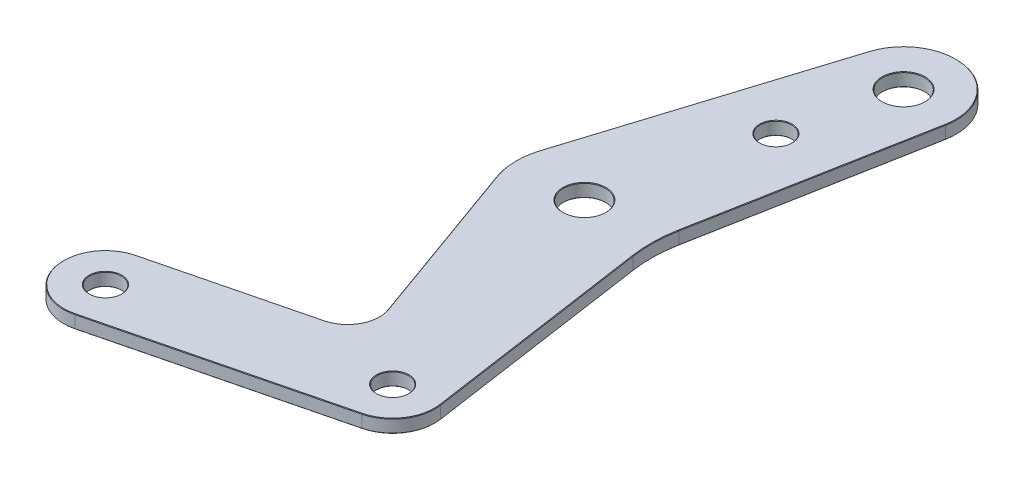
from build123d import *

# Parameters (mm, degrees)
SKETCH1_R           = 4
SKETCH1_R_2         = 3
BOSS_EXTRUDE1_DEPTH = 1.25
CHAMFER1_SIZE       = 0.1


with BuildPart() as part:
    # Sketch1 → Boss-Extrude1 (new body, symmetric)
    with BuildSketch(Plane(origin=(0, 0, 0), x_dir=(1, 0, 0), z_dir=(0, 1, 0))):
        with BuildLine():
            Line((-29.631837738, -67.163637426), (14.031469945, -56.277152124))
            ThreePointArc((14.031469945, -56.277152124), (18.738560702, -52.973221742), (20.01308876, -47.36534892))
            Line((20.01308876, -47.36534892), (13.793825748, -4.528855104))
            ThreePointArc((13.793825748, -4.528855104), (13.529290218, -0.271510867), (13.964419925, 3.971792226))
            Line((13.964419925, 3.971792226), (21.92672411, 46.682103314))
            ThreePointArc((21.92672411, 46.682103314), (14.515313736, 58.217743577), (2.555771725, 51.511824185))
            Line((2.555771725, 51.511824185), (-12.402419972, 3.896149233))
            ThreePointArc((-12.402419972, 3.896149233), (-12.997382983, -0.260836353), (-12.236118289, -4.390604654))
            Line((-12.236118289, -4.390604654), (-0.66120456, -36.648579291))
            ThreePointArc((-0.66120456, -36.648579291), (-1.017383505, -41.503892695), (-4.857112397, -44.496786566))
            Line((-4.857112397, -44.496786566), (-33.502588067, -51.638905806))
            ThreePointArc((-33.502588067, -51.638905806), (-39.329578713, -61.336646781), (-29.631837738, -67.163637426))
        make_face()
        Circle(SKETCH1_R, mode=Mode.SUBTRACT)
        with Locations((12.09609478, 48.514786314)):
            Circle(SKETCH1_R, mode=Mode.SUBTRACT)
        with Locations((7.257656868, 29.108871788)):
            Circle(SKETCH1_R_2, mode=Mode.SUBTRACT)
        with Locations((12.09609478, -48.514786314)):
            Circle(SKETCH1_R_2, mode=Mode.SUBTRACT)
        with Locations((-31.567212902, -59.401271616)):
            Circle(SKETCH1_R_2, mode=Mode.SUBTRACT)
    extrude(amount=BOSS_EXTRUDE1_DEPTH, both=True)

    # Chamfer1
    chamfer1_edges = [part.edges().sort_by_distance(p)[0] for p in [
        (-39.329578713, 1.25, 61.336646781),
        (-6.448661425, -1.25, 20.519591973),
        (-12.997382983, -1.25, 0.260836353),
        (-4.923324123, -1.25, -27.703986709),
        (14.515313736, -1.25, -58.217743577),
        (17.945572018, -1.25, -25.32694777),
        (13.529290218, -1.25, 0.271510867),
        (-7.800183896, 1.25, 61.720394775),
        (16.903457254, -1.25, 25.947102012),
        (18.738560702, -1.25, 52.973221742),
        (-7.800183896, -1.25, 61.720394775),
        (-39.329578713, -1.25, 61.336646781),
        (-19.179850232, -1.25, 48.067846186),
        (-1.017383505, -1.25, 41.503892695),
        (18.738560702, 1.25, 52.973221742),
        (16.903457254, 1.25, 25.947102012),
        (13.529290218, 1.25, 0.271510867),
        (17.945572018, 1.25, -25.32694777),
        (14.515313736, 1.25, -58.217743577),
        (-4, -1.25, 0),
        (-4, 1.25, 0),
        (-4.923324123, 1.25, -27.703986709),
        (8.09609478, -1.25, -48.514786314),
        (8.09609478, 1.25, -48.514786314),
        (-12.997382983, 1.25, 0.260836353),
        (-6.448661425, 1.25, 20.519591973),
        (4.257656868, -1.25, -29.108871788),
        (4.257656868, 1.25, -29.108871788),
        (-1.017383505, 1.25, 41.503892695),
        (9.09609478, -1.25, 48.514786314),
        (9.09609478, 1.25, 48.514786314),
        (-34.567212902, -1.25, 59.401271616),
        (-34.567212902, 1.25, 59.401271616),
        (-19.179850232, 1.25, 48.067846186),
    ]]
    chamfer(chamfer1_edges, length=CHAMFER1_SIZE)


solid = part.part
